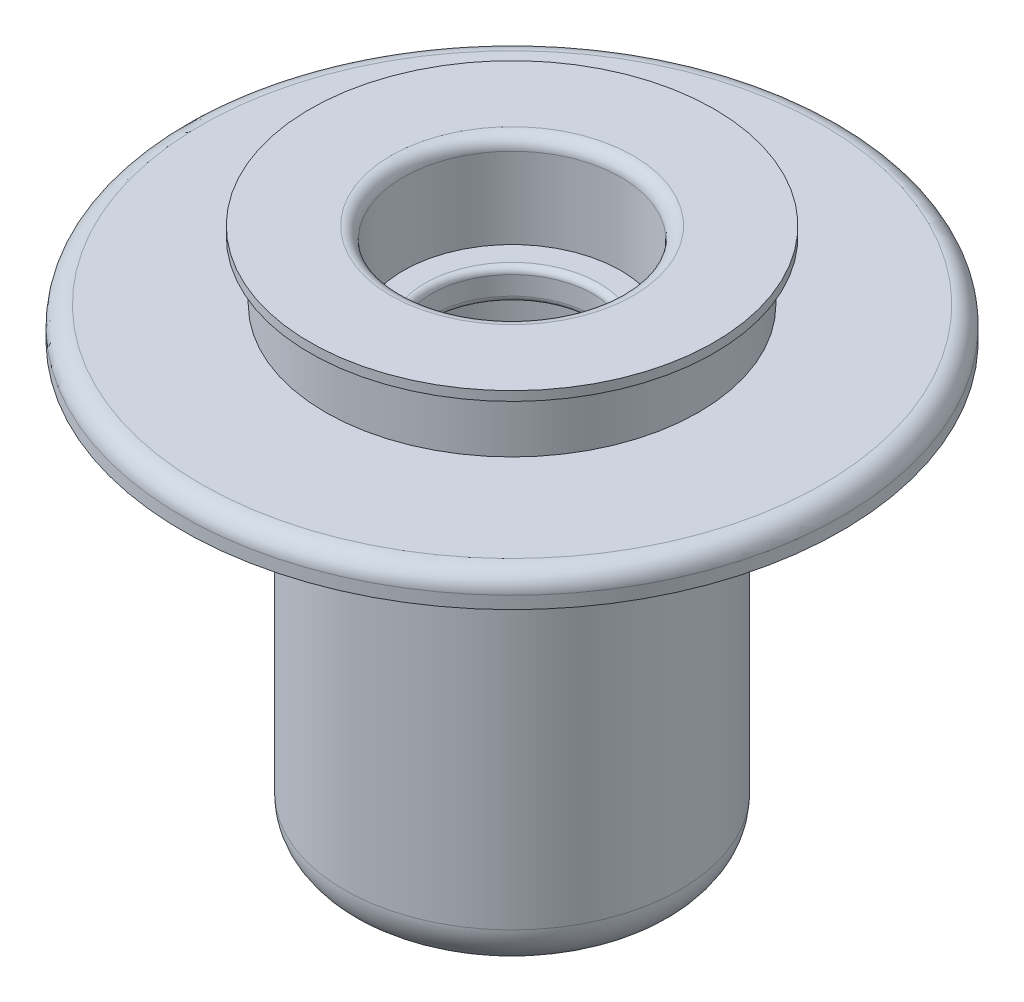
from build123d import *

# Parameters (mm, degrees)
ESQUISSE4_W             = 38
ESQUISSE4_H             = 11.5
ENL_V_MAT_EXTRU_1_DEPTH = 40


with BuildPart() as part:
    # Esquisse1 → Révolution1 (revolve)
    with BuildSketch(Plane.XY):
        with BuildLine():
            Line((19.5, 95.758251599), (32.5, 95.758251599))
            Line((32.5, 95.758251599), (32.5, 94.258251599))
            Line((32.5, 94.258251599), (30, 94.258251599))
            Line((30, 94.258251599), (30, 84.758251599))
            Line((30, 84.758251599), (50, 84.758251599))
            ThreePointArc((50, 84.758251599), (52.121320344, 83.879571943), (53, 81.758251599))
            Line((53, 81.758251599), (53, 79.758251599))
            Line((53, 79.758251599), (27, 79.758251599))
            Line((27, 79.758251599), (27, 16.758251599))
            ThreePointArc((27, 16.758251599), (24.949747468, 11.808504131), (20, 9.758251599))
            Line((20, 9.758251599), (12.5, 9.758251599))
            Line((12.5, 9.758251599), (12.5, 18.758251599))
            ThreePointArc((12.5, 18.758251599), (12.792893219, 19.46535838), (13.5, 19.758251599))
            Line((13.5, 19.758251599), (17.5, 19.758251599))
            Line((17.5, 19.758251599), (17.5, 30.758251599))
            Line((17.5, 30.758251599), (14, 30.758251599))
            ThreePointArc((14, 30.758251599), (13.292893219, 31.051144818), (13, 31.758251599))
            Line((13, 31.758251599), (13, 34.758251599))
            ThreePointArc((13, 34.758251599), (13.292893219, 35.46535838), (14, 35.758251599))
            Line((14, 35.758251599), (22, 35.758251599))
            Line((22, 35.758251599), (22, 75.758251599))
            Line((22, 75.758251599), (14, 75.758251599))
            ThreePointArc((14, 75.758251599), (13.292893219, 76.051144818), (13, 76.758251599))
            Line((13, 76.758251599), (13, 79.758251599))
            ThreePointArc((13, 79.758251599), (13.292893219, 80.46535838), (14, 80.758251599))
            Line((14, 80.758251599), (17.5, 80.758251599))
            Line((17.5, 80.758251599), (17.5, 93.758251599))
            ThreePointArc((17.5, 93.758251599), (18.085786438, 95.172465162), (19.5, 95.758251599))
        make_face()
    revolve(axis=Axis((0, 0, 0), (0, 1, 0)))

    # Esquisse4 → Enlèv. mat.-Extru.1 (cut)
    with BuildSketch(Plane.XY):
        with Locations((0, 25)):
            Rectangle(ESQUISSE4_W, ESQUISSE4_H)
    extrude(amount=-ENL_V_MAT_EXTRU_1_DEPTH, mode=Mode.SUBTRACT)


solid = part.part
